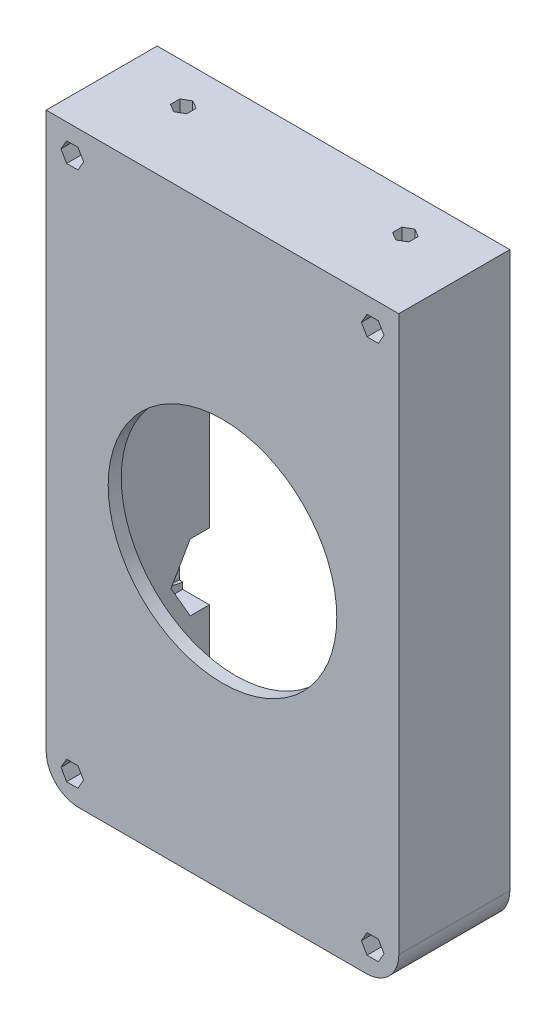
from build123d import *

# Parameters (mm, degrees)
SKETCH1_W           = 54
SKETCH1_H           = 90
SKETCH1_W_2         = 38
SKETCH1_H_2         = 74
BOSS_EXTRUDE1_DEPTH = 30
CUT_EXTRUDE1_DEPTH  = 4.1
SKETCH5_R           = 4.1
CUT_EXTRUDE2_DEPTH  = 0.5
CUT_EXTRUDE3_DEPTH  = 4.1
SKETCH7_R           = 4.1
CUT_EXTRUDE4_DEPTH  = 0.5
SKETCH8_W           = 54
SKETCH8_H           = 90
BOSS_EXTRUDE2_DEPTH = 2
SKETCH9_W           = 54
SKETCH9_H           = 90
BOSS_EXTRUDE3_DEPTH = 2
SKETCH12_W          = 54
SKETCH12_H          = 90
CUT_EXTRUDE7_DEPTH  = 17
CUT_EXTRUDE8_DEPTH  = 18
SKETCH14_R          = 17.5
CUT_EXTRUDE9_DEPTH  = 3
CUT_EXTRUDE10_DEPTH = 5
FILLET1_R           = 5


with BuildPart() as part:
    # Sketch1 → Boss-Extrude1 (new body)
    with BuildSketch(Plane.XY):
        with Locations((27, 45)):
            Rectangle(SKETCH1_W, SKETCH1_H)
        with Locations((27, 45)):
            Rectangle(SKETCH1_W_2, SKETCH1_H_2, mode=Mode.SUBTRACT)
    extrude(amount=BOSS_EXTRUDE1_DEPTH)

    # Sketch2 → Cut-Extrude1 (cut)
    with BuildSketch(Plane.ZY.offset(-46)):
        Polygon((20.888972746, 65), (17.944486373, 70.1), (12.055513627, 70.1), (9.111027254, 65), (12.055513627, 59.9), (17.944486373, 59.9), align=None)
        Polygon((20.888972746, 25), (17.944486373, 30.1), (12.055513627, 30.1), (9.111027254, 25), (12.055513627, 19.9), (17.944486373, 19.9), align=None)
    extrude(amount=-CUT_EXTRUDE1_DEPTH, mode=Mode.SUBTRACT)

    # Sketch5 → Cut-Extrude2 (cut)
    with BuildSketch(Plane.ZY.offset(-50.1)):
        with Locations((15, 65)):
            Circle(SKETCH5_R)
        with Locations((15, 25)):
            Circle(SKETCH5_R)
    extrude(amount=-CUT_EXTRUDE2_DEPTH, mode=Mode.SUBTRACT)

    # Sketch6 → Cut-Extrude3 (cut)
    with BuildSketch(Plane(origin=(8, 0, 0), x_dir=(0, 0, -1), z_dir=(1, 0, 0))):
        Polygon((-9.111027254, 65), (-12.055513627, 70.1), (-17.944486373, 70.1), (-20.888972746, 65), (-17.944486373, 59.9), (-12.055513627, 59.9), align=None)
        Polygon((-9.111027254, 25), (-12.055513627, 30.1), (-17.944486373, 30.1), (-20.888972746, 25), (-17.944486373, 19.9), (-12.055513627, 19.9), align=None)
    extrude(amount=-CUT_EXTRUDE3_DEPTH, mode=Mode.SUBTRACT)

    # Sketch7 → Cut-Extrude4 (cut)
    with BuildSketch(Plane(origin=(3.9, 0, 0), x_dir=(0, 0, -1), z_dir=(1, 0, 0))):
        with Locations((-15, 65)):
            Circle(SKETCH7_R)
        with Locations((-15, 25)):
            Circle(SKETCH7_R)
    extrude(amount=-CUT_EXTRUDE4_DEPTH, mode=Mode.SUBTRACT)

    # Sketch8 → Boss-Extrude2 (add)
    with BuildSketch(Plane.XY.offset(30)):
        with Locations((27, 45)):
            Rectangle(SKETCH8_W, SKETCH8_H)
    extrude(amount=BOSS_EXTRUDE2_DEPTH)

    # Sketch9 → Boss-Extrude3 (add)
    with BuildSketch(Plane(origin=(0, 0, 0), x_dir=(-1, 0, 0), z_dir=(0, 0, -1))):
        with Locations((-27, 45)):
            Rectangle(SKETCH9_W, SKETCH9_H)
    extrude(amount=BOSS_EXTRUDE3_DEPTH)

    # Sketch12 → Cut-Extrude7 (cut)
    with BuildSketch(Plane(origin=(0, 0, -2), x_dir=(-1, 0, 0), z_dir=(0, 0, -1))):
        with Locations((-27, 45)):
            Rectangle(SKETCH12_W, SKETCH12_H)
    extrude(amount=-CUT_EXTRUDE7_DEPTH, mode=Mode.SUBTRACT)

    # Sketch13 → Cut-Extrude8 (cut, through all)
    with BuildSketch(Plane(origin=(0, 0, 15), x_dir=(-1, 0, 0), z_dir=(0, 0, -1))):
        Polygon((-48.267949192, 86), (-49.133974596, 87.5), (-50.866025404, 87.5), (-51.732050808, 86), (-50.866025404, 84.5), (-49.133974596, 84.5), align=None)
        Polygon((-2.267949192, 86), (-3.133974596, 87.5), (-4.866025404, 87.5), (-5.732050808, 86), (-4.866025404, 84.5), (-3.133974596, 84.5), align=None)
        Polygon((-48.267949192, 4), (-49.133974596, 5.5), (-50.866025404, 5.5), (-51.732050808, 4), (-50.866025404, 2.5), (-49.133974596, 2.5), align=None)
        Polygon((-5.732050808, 4), (-4.866025404, 2.5), (-3.133974596, 2.5), (-2.267949192, 4), (-3.133974596, 5.5), (-4.866025404, 5.5), align=None)
    extrude(amount=-CUT_EXTRUDE8_DEPTH, mode=Mode.SUBTRACT)

    # Sketch14 → Cut-Extrude9 (cut, through all)
    with BuildSketch(Plane(origin=(0, 0, 30), x_dir=(-1, 0, 0), z_dir=(0, 0, -1))):
        with Locations((-27, 45)):
            Circle(SKETCH14_R)
    extrude(amount=-CUT_EXTRUDE9_DEPTH, mode=Mode.SUBTRACT)

    # Sketch15 → Cut-Extrude10 (cut)
    with BuildSketch(Plane(origin=(0, 90, 0), x_dir=(1, 0, 0), z_dir=(0, 1, 0))):
        Polygon((10, -19.556624327), (8.75, -20.278312164), (8.75, -21.721687836), (10, -22.443375673), (11.25, -21.721687836), (11.25, -20.278312164), align=None)
        Polygon((44, -19.556624327), (42.75, -20.278312164), (42.75, -21.721687836), (44, -22.443375673), (45.25, -21.721687836), (45.25, -20.278312164), align=None)
    extrude(amount=-CUT_EXTRUDE10_DEPTH, mode=Mode.SUBTRACT)

    # Fillet1
    fillet1_edges = [part.edges().sort_by_distance(p)[0] for p in [
        (54, 0, 23.5),
        (0, 0, 23.5),
    ]]
    fillet(fillet1_edges, radius=FILLET1_R)


solid = part.part
